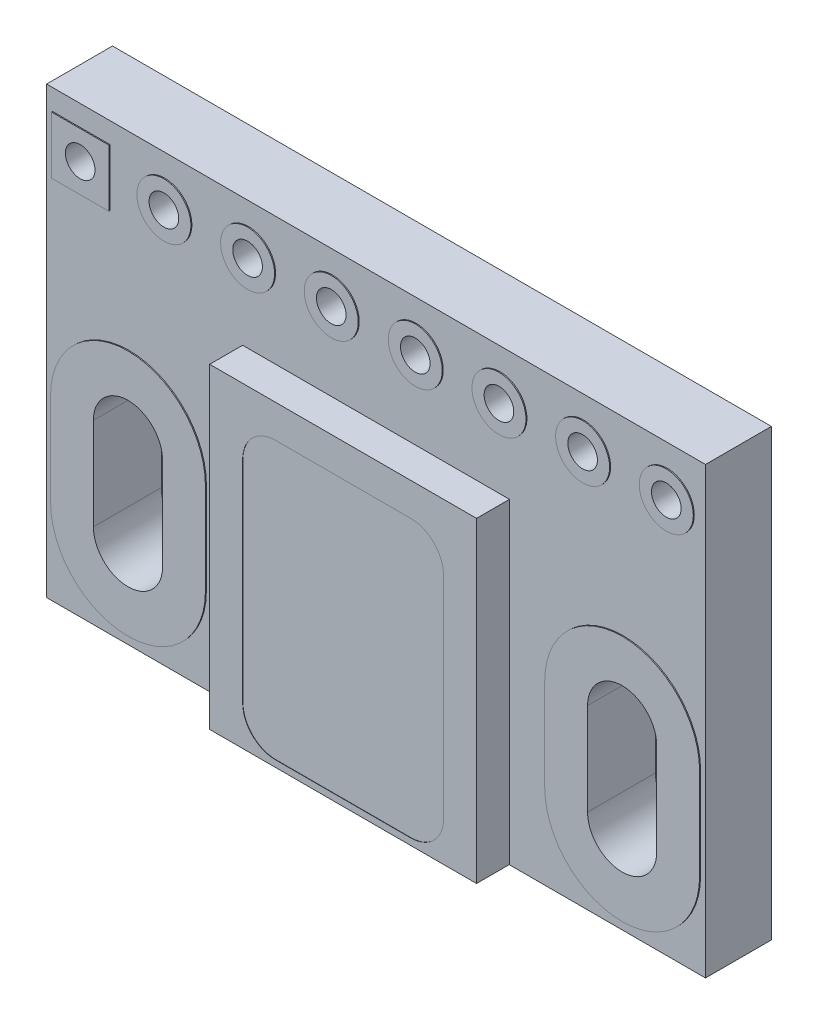
from build123d import *

# Parameters (mm, degrees)
SKETCH1_W                = 20
SKETCH1_H                = 13.500001
SKETCH1_R                = 0.45
BOSS_EXTRUDE1_DEPTH      = 2
SKETCH2_R                = 0.819603139
SKETCH2_R_2              = 0.45
SKETCH2_W                = 1.738984036
SKETCH2_H                = 1.738984036
BOSS_EXTRUDE2_DEPTH      = 0.03
BOSS_EXTRUDE2_DEPTH_BACK = 2.03
SKETCH3_W                = 8.1
SKETCH3_H                = 9.6
BOSS_EXTRUDE3_DEPTH      = 1
SKETCH4_W                = 4
SKETCH4_H                = 4
BOSS_EXTRUDE4_DEPTH      = 0.9
SKETCH5_W                = 8.1
SKETCH5_H                = 4.8
BOSS_EXTRUDE5_DEPTH      = 1
CUT_EXTRUDE1_DEPTH       = 0.01
CUT_EXTRUDE2_DEPTH       = 0.01
SKETCH8_W                = 0.999631569
SKETCH8_H                = 0.989635253
SKETCH8_W_2              = 1.011864782
BOSS_EXTRUDE6_DEPTH      = 0.03
BOSS_EXTRUDE7_DEPTH      = 1
CUT_EXTRUDE3_DEPTH       = 2.6
SKETCH11_W               = 0.533099155
SKETCH11_H               = 1.043933413
SKETCH11_W_2             = 0.526574326
SKETCH11_H_2             = 1.054342849
BOSS_EXTRUDE8_DEPTH      = 0.5
SKETCH12_W               = 0.790233591
SKETCH12_H               = 0.528353854
SKETCH12_W_2             = 0.781044828
SKETCH12_H_2             = 0.588080812
CUT_EXTRUDE4_DEPTH       = 0.01


with BuildPart() as part:
    # Sketch1 → Boss-Extrude1 (new body)
    with BuildSketch(Plane.XY):
        with Locations((245.999999, 244.7499975)):
            Rectangle(SKETCH1_W, SKETCH1_H)
        with Locations((237.05, 250)):
            Circle(SKETCH1_R, mode=Mode.SUBTRACT)
        with Locations((239.59, 250)):
            Circle(SKETCH1_R, mode=Mode.SUBTRACT)
        with Locations((242.13, 250)):
            Circle(SKETCH1_R, mode=Mode.SUBTRACT)
        with Locations((244.67, 250)):
            Circle(SKETCH1_R, mode=Mode.SUBTRACT)
        with Locations((247.22, 250)):
            Circle(SKETCH1_R, mode=Mode.SUBTRACT)
        with Locations((249.76, 250)):
            Circle(SKETCH1_R, mode=Mode.SUBTRACT)
        with Locations((252.3, 250)):
            Circle(SKETCH1_R, mode=Mode.SUBTRACT)
        with Locations((254.84, 250)):
            Circle(SKETCH1_R, mode=Mode.SUBTRACT)
        with BuildLine():
            Line((239.549999, 243.399997), (239.549999, 240.599997))
            ThreePointArc((239.549999, 240.599997), (238.499999, 239.549997), (237.449999, 240.599997))
            Line((237.449999, 240.599997), (237.449999, 243.399997))
            ThreePointArc((237.449999, 243.399997), (238.499999, 244.449997), (239.549999, 243.399997))
        make_face(mode=Mode.SUBTRACT)
        with BuildLine():
            Line((254.549999, 243.399997), (254.549999, 240.599997))
            ThreePointArc((254.549999, 240.599997), (253.499999, 239.549997), (252.449999, 240.599997))
            Line((252.449999, 240.599997), (252.449999, 243.399997))
            ThreePointArc((252.449999, 243.399997), (253.499999, 244.449997), (254.549999, 243.399997))
        make_face(mode=Mode.SUBTRACT)
    extrude(amount=BOSS_EXTRUDE1_DEPTH)

    # Sketch2 → Boss-Extrude2 (add, two sides)
    with BuildSketch(Plane.XY.offset(2)) as boss_extrude2_sk:
        with Locations((254.84, 250)):
            Circle(SKETCH2_R)
        with Locations((254.84, 250)):
            Circle(SKETCH2_R_2, mode=Mode.SUBTRACT)
        with Locations((252.3, 250)):
            Circle(SKETCH2_R)
        with Locations((252.3, 250)):
            Circle(SKETCH2_R_2, mode=Mode.SUBTRACT)
        with Locations((249.76, 250)):
            Circle(SKETCH2_R)
        with Locations((249.76, 250)):
            Circle(SKETCH2_R_2, mode=Mode.SUBTRACT)
        with Locations((247.22, 250)):
            Circle(SKETCH2_R)
        with Locations((247.22, 250)):
            Circle(SKETCH2_R_2, mode=Mode.SUBTRACT)
        with Locations((244.67, 250)):
            Circle(SKETCH2_R)
        with Locations((244.67, 250)):
            Circle(SKETCH2_R_2, mode=Mode.SUBTRACT)
        with Locations((242.13, 250)):
            Circle(SKETCH2_R)
        with Locations((242.13, 250)):
            Circle(SKETCH2_R_2, mode=Mode.SUBTRACT)
        with Locations((239.59, 250)):
            Circle(SKETCH2_R)
        with Locations((239.59, 250)):
            Circle(SKETCH2_R_2, mode=Mode.SUBTRACT)
        with Locations((237.05, 250)):
            Rectangle(SKETCH2_W, SKETCH2_H)
        with Locations((237.05, 250)):
            Circle(SKETCH2_R_2, mode=Mode.SUBTRACT)
        with BuildLine():
            Line((240.849999, 240.599997), (240.849999, 243.399997))
            ThreePointArc((240.849999, 243.399997), (238.499999, 245.749997), (236.149999, 243.399997))
            Line((236.149999, 243.399997), (236.149999, 240.599997))
            ThreePointArc((236.149999, 240.599997), (238.499999, 238.249997), (240.849999, 240.599997))
        make_face()
        with BuildLine():
            Line((239.549999, 240.599997), (239.549999, 243.399997))
            ThreePointArc((239.549999, 243.399997), (238.499999, 244.449997), (237.449999, 243.399997))
            Line((237.449999, 243.399997), (237.449999, 240.599997))
            ThreePointArc((237.449999, 240.599997), (238.499999, 239.549997), (239.549999, 240.599997))
        make_face(mode=Mode.SUBTRACT)
        with BuildLine():
            Line((255.849999, 240.599997), (255.849999, 243.399997))
            ThreePointArc((255.849999, 243.399997), (253.499999, 245.749997), (251.149999, 243.399997))
            Line((251.149999, 243.399997), (251.149999, 240.599997))
            ThreePointArc((251.149999, 240.599997), (253.499999, 238.249997), (255.849999, 240.599997))
        make_face()
        with BuildLine():
            Line((254.549999, 240.599997), (254.549999, 243.399997))
            ThreePointArc((254.549999, 243.399997), (253.499999, 244.449997), (252.449999, 243.399997))
            Line((252.449999, 243.399997), (252.449999, 240.599997))
            ThreePointArc((252.449999, 240.599997), (253.499999, 239.549997), (254.549999, 240.599997))
        make_face(mode=Mode.SUBTRACT)
    extrude(amount=BOSS_EXTRUDE2_DEPTH)
    extrude(boss_extrude2_sk.sketch, amount=-BOSS_EXTRUDE2_DEPTH_BACK)

    # Sketch3 → Boss-Extrude3 (add)
    with BuildSketch(Plane.XY.offset(2)):
        with Locations((245.999999, 242.808292715)):
            Rectangle(SKETCH3_W, SKETCH3_H)
    extrude(amount=BOSS_EXTRUDE3_DEPTH)

    # Sketch4 → Boss-Extrude4 (add)
    with BuildSketch(Plane(origin=(0, 0, 0), x_dir=(-1, 0, 0), z_dir=(0, 0, -1))):
        with Locations((-246.445106078, 245.84618694)):
            Rectangle(SKETCH4_W, SKETCH4_H)
    extrude(amount=BOSS_EXTRUDE4_DEPTH)

    # Sketch5 → Boss-Extrude5 (add)
    with BuildSketch(Plane(origin=(0, 0, 0), x_dir=(-1, 0, 0), z_dir=(0, 0, -1))):
        with Locations((-245.999999, 240.408292715)):
            Rectangle(SKETCH5_W, SKETCH5_H)
    extrude(amount=BOSS_EXTRUDE5_DEPTH)

    # Sketch6 → Cut-Extrude1 (cut)
    with BuildSketch(Plane(origin=(0, 0, -1), x_dir=(-1, 0, 0), z_dir=(0, 0, -1))):
        with BuildLine():
            Line((-243.949999, 238.208292715), (-248.049999, 238.208292715))
            ThreePointArc((-248.049999, 238.208292715), (-248.757105781, 238.501185934), (-249.049999, 239.208292715))
            Line((-249.049999, 239.208292715), (-249.049999, 240.808292715))
            ThreePointArc((-249.049999, 240.808292715), (-248.757105781, 241.515399497), (-248.049999, 241.808292715))
            Line((-248.049999, 241.808292715), (-243.949999, 241.808292715))
            ThreePointArc((-243.949999, 241.808292715), (-243.242892219, 241.515399497), (-242.949999, 240.808292715))
            Line((-242.949999, 240.808292715), (-242.949999, 239.208292715))
            ThreePointArc((-242.949999, 239.208292715), (-243.242892219, 238.501185934), (-243.949999, 238.208292715))
        make_face()
    extrude(amount=-CUT_EXTRUDE1_DEPTH, mode=Mode.SUBTRACT)

    # Sketch7 → Cut-Extrude2 (cut)
    with BuildSketch(Plane.XY.offset(3)):
        with BuildLine():
            Line((248.049999, 238.208292715), (243.949999, 238.208292715))
            ThreePointArc((243.949999, 238.208292715), (243.242892219, 238.501185934), (242.949999, 239.208292715))
            Line((242.949999, 239.208292715), (242.949999, 245.608292715))
            ThreePointArc((242.949999, 245.608292715), (243.242892219, 246.315399497), (243.949999, 246.608292715))
            Line((243.949999, 246.608292715), (248.049999, 246.608292715))
            ThreePointArc((248.049999, 246.608292715), (248.757105781, 246.315399497), (249.049999, 245.608292715))
            Line((249.049999, 245.608292715), (249.049999, 239.208292715))
            ThreePointArc((249.049999, 239.208292715), (248.757105781, 238.501185934), (248.049999, 238.208292715))
        make_face()
    extrude(amount=-CUT_EXTRUDE2_DEPTH, mode=Mode.SUBTRACT)

    # Sketch8 → Boss-Extrude6 (add)
    with BuildSketch(Plane(origin=(0, 0, 0), x_dir=(-1, 0, 0), z_dir=(0, 0, -1))):
        with Locations((-237.15577341, 247.619765465)):
            Rectangle(SKETCH8_W, SKETCH8_H)
        with Locations((-238.609118894, 247.619765465)):
            Rectangle(SKETCH8_W_2, SKETCH8_H)
    extrude(amount=BOSS_EXTRUDE6_DEPTH)

    # Sketch9 → Boss-Extrude7 (add)
    with BuildSketch(Plane(origin=(0, 0, 0), x_dir=(-1, 0, 0), z_dir=(0, 0, -1))):
        Polygon((-241.285710455, 245.57978186), (-242.345502954, 245.57978186), (-242.345502954, 245.160465509), (-242.585710455, 245.160465509), (-242.585710455, 245.57978186), (-242.819313656, 245.57978186), (-242.819313656, 246.831260128), (-242.585710455, 246.831260128), (-242.585710455, 247.294770598), (-242.345502954, 247.294770598), (-242.345502954, 246.831260128), (-241.938643764, 246.831260128), (-241.938643764, 247.294770598), (-241.701738413, 247.294770598), (-241.701738413, 246.831260128), (-241.285710455, 246.831260128), (-241.285710455, 247.294770598), (-241.052823755, 247.294770598), (-241.052823755, 246.831260128), (-240.805618171, 246.831260128), (-240.805618171, 245.57978186), (-241.052823755, 245.57978186), (-241.052823755, 245.160465509), (-241.285710455, 245.160465509), align=None)
    extrude(amount=BOSS_EXTRUDE7_DEPTH)

    # Sketch10 → Cut-Extrude3 (cut)
    with BuildSketch(Plane.ZY.offset(-240.805618171)):
        Polygon((-0.139914532, 247.261149036), (-0.139914532, 247.654280251), (-1.139334449, 247.6306482), (-1.139334449, 246.768139286), (-0.664914532, 246.831260128), (-0.659522719, 246.947275532), (-0.617686325, 247.030225677), (-0.571030714, 247.070675895), (-0.464914532, 247.101149036), (-0.214914532, 247.101149036), (-0.175120964, 247.112576464), (-0.139914532, 247.176149036), align=None)
        Polygon((-0.168849562, 244.714491458), (-1.19001655, 244.714491458), (-1.19001655, 245.593519078), (-0.69247485, 245.57978186), (-0.688445892, 245.463351864), (-0.633037025, 245.36229342), (-0.537638862, 245.312360298), (-0.428113234, 245.309473852), (-0.241853581, 245.309473852), (-0.194919318, 245.294889416), (-0.168849562, 245.24734163), align=None)
        Polygon((0, 247.137992097), (0, 245.271934602), (-0.018624988, 245.313290797), (-0.03, 245.334037315), (-0.080158557, 245.398416567), (-0.13585172, 245.434693764), (-0.192582949, 245.452322526), (-0.480159045, 245.452322526), (-0.525933569, 245.466546583), (-0.551279805, 245.512774766), (-0.551279805, 245.57978186), (-0.122872548, 245.594606519), (-0.122872548, 246.820664687), (-0.524914532, 246.831260128), (-0.524914532, 246.881321064), (-0.518359906, 246.911984247), (-0.490443439, 246.944427385), (-0.449914532, 246.956321064), (-0.199914532, 246.956321064), (-0.122872548, 246.971755269), (-0.058493176, 247.014899708), (-0.019914532, 247.061570174), align=None)
    extrude(amount=-CUT_EXTRUDE3_DEPTH, mode=Mode.SUBTRACT)

    # Sketch11 → Boss-Extrude8 (add)
    with BuildSketch(Plane(origin=(0, 0, 0), x_dir=(-1, 0, 0), z_dir=(0, 0, -1))):
        with Locations((-249.893103136, 246.681229126)):
            Rectangle(SKETCH11_W, SKETCH11_H)
        with Locations((-250.966067395, 246.735980044)):
            Rectangle(SKETCH11_W_2, SKETCH11_H_2)
    extrude(amount=BOSS_EXTRUDE8_DEPTH)

    # Sketch12 → Cut-Extrude4 (cut)
    with BuildSketch(Plane(origin=(0, 0, -0.5), x_dir=(-1, 0, 0), z_dir=(0, 0, -1))):
        with Locations((-249.900037949, 246.670373318)):
            Rectangle(SKETCH12_W, SKETCH12_H)
        with Locations((-250.956745657, 246.74618061)):
            Rectangle(SKETCH12_W_2, SKETCH12_H_2)
    extrude(amount=-CUT_EXTRUDE4_DEPTH, mode=Mode.SUBTRACT)


solid = part.part
